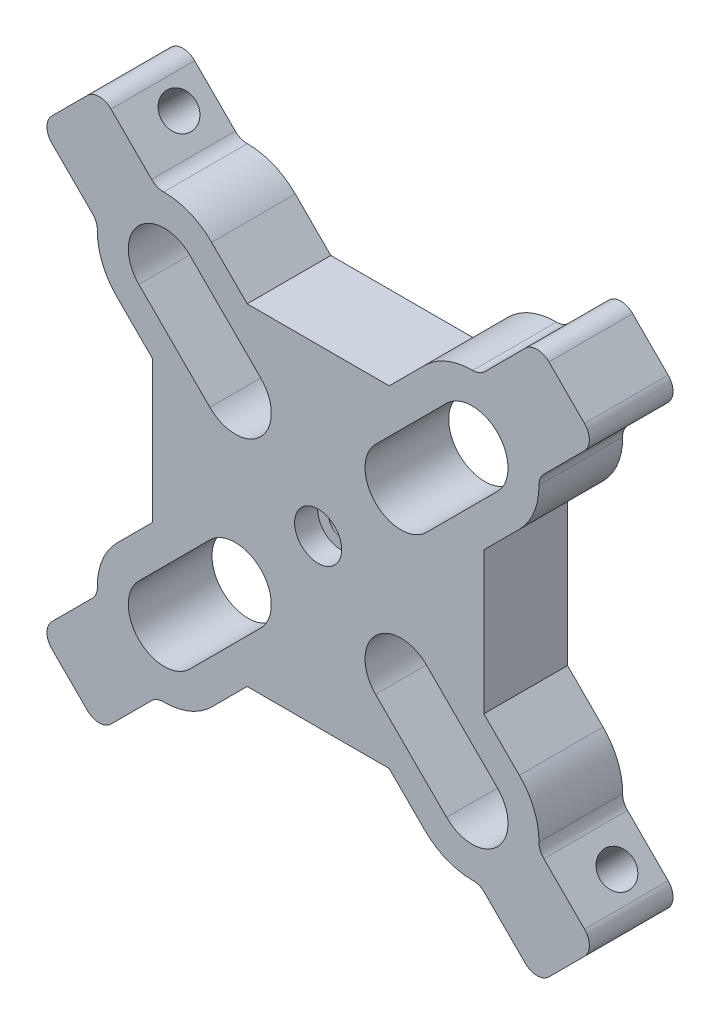
from build123d import *

# Parameters (mm, degrees)
SKETCH1_W                                      = 71.12
SKETCH1_H                                      = 71.12
EXTRUDE1_DEPTH                                 = 12.7
SKETCH3_R                                      = 2.921
CUT_EXTRUDE1_DEPTH                             = 102.377506381
MIRROR3_COPY_1_SKETCH_R                        = 2.921
MIRROR3_COPY_1_DEPTH                           = 102.377506381
MIRROR3_COPY_2_SKETCH_R                        = 2.921
MIRROR3_COPY_2_DEPTH                           = 102.377506381
SKETCH6_R                                      = 5.461
CUT_EXTRUDE3_DEPTH                             = 102.377506381
MIRROR6_COPY_1_SKETCH_R                        = 5.461
MIRROR6_COPY_1_DEPTH                           = 102.377506381
MIRROR6_COPY_2_SKETCH_R                        = 5.461
MIRROR6_COPY_2_DEPTH                           = 102.377506381
SKETCH7_W                                      = 71.12
SKETCH7_H                                      = 71.12
CUT_EXTRUDE5_DEPTH                             = 102.377506381
EXTRUDE2_DEPTH                                 = 12.7
CBORE_FOR_6_SOCKET_HEAD_CAP_SCREW1_D           = 3.7973
CBORE_FOR_6_SOCKET_HEAD_CAP_SCREW1_CBORE_D     = 7.14502
CBORE_FOR_6_SOCKET_HEAD_CAP_SCREW1_CBORE_DEPTH = 3.5052
MIRROR9_COPY_1_DEPTH                           = 12.7
FILLET3_R                                      = 2.54


with BuildPart() as part:
    # Sketch1 → Extrude1 (new body)
    with BuildSketch(Plane.XY):
        with Locations((-35.56, 35.56)):
            Rectangle(SKETCH1_W, SKETCH1_H)
    extrude(amount=EXTRUDE1_DEPTH)

    # Sketch3 → Cut-Extrude1 (cut, through all)
    with BuildSketch(Plane.XY.offset(12.7)):
        with Locations((-58.908665915, 58.908665915)):
            Circle(SKETCH3_R)
        with Locations((-48.132358569, 48.132358569)):
            Circle(SKETCH3_R)
        Polygon((-58.908665915, 58.908665915), (-56.843207007, 60.974124823), (-46.066899662, 50.197817477), (-50.197817477, 46.066899662), (-60.974124823, 56.843207007), align=None)
    cut_extrude1 = extrude(amount=-CUT_EXTRUDE1_DEPTH, mode=Mode.SUBTRACT)

    # Mirror1: Cut-Extrude1 across plane
    add(cut_extrude1.mirror(Plane.ZX.offset(35.56)), mode=Mode.SUBTRACT)

    # Mirror2: Cut-Extrude1 across plane
    add(cut_extrude1.mirror(Plane(origin=(-35.56, 0, 0), x_dir=(0, 0, 1), z_dir=(1, 0, 0))), mode=Mode.SUBTRACT)

    # Mirror3 copy 1 sketch → Mirror3 copy 1 (cut, through all)
    with BuildSketch(Plane(origin=(-71.12, 71.12, 12.7), x_dir=(-1, 0, 0), z_dir=(0, 0, 1))):
        with Locations((-58.908665915, 58.908665915)):
            Circle(MIRROR3_COPY_1_SKETCH_R)
        with Locations((-48.132358569, 48.132358569)):
            Circle(MIRROR3_COPY_1_SKETCH_R)
        Polygon((-58.908665915, 58.908665915), (-56.843207007, 60.974124823), (-46.066899662, 50.197817477), (-50.197817477, 46.066899662), (-60.974124823, 56.843207007), align=None)
    extrude(amount=-MIRROR3_COPY_1_DEPTH, mode=Mode.SUBTRACT)

    # Mirror3 copy 2 sketch → Mirror3 copy 2 (cut, through all)
    with BuildSketch(Plane(origin=(0, 71.12, 12.7), x_dir=(1, 0, 0), z_dir=(0, 0, 1))):
        with Locations((-58.908665915, -58.908665915)):
            Circle(MIRROR3_COPY_2_SKETCH_R)
        with Locations((-48.132358569, -48.132358569)):
            Circle(MIRROR3_COPY_2_SKETCH_R)
        Polygon((-58.908665915, -58.908665915), (-56.843207007, -60.974124823), (-46.066899662, -50.197817477), (-50.197817477, -46.066899662), (-60.974124823, -56.843207007), align=None)
    extrude(amount=-MIRROR3_COPY_2_DEPTH, mode=Mode.SUBTRACT)

    # Sketch6 → Cut-Extrude3 (cut, through all)
    with BuildSketch(Plane.XY.offset(12.7)):
        with Locations((-58.908665915, 58.908665915)):
            Circle(SKETCH6_R)
        with Locations((-48.132358569, 48.132358569)):
            Circle(SKETCH6_R)
        Polygon((-58.908665915, 58.908665915), (-55.047155783, 62.770176047), (-44.270848437, 51.993868702), (-48.132358569, 48.132358569), (-51.993868702, 44.270848437), (-62.770176047, 55.047155783), align=None)
    cut_extrude3 = extrude(amount=-CUT_EXTRUDE3_DEPTH, mode=Mode.SUBTRACT)

    # Mirror4: Cut-Extrude3 across plane
    add(cut_extrude3.mirror(Plane(origin=(-35.56, 0, 0), x_dir=(0, 0, 1), z_dir=(1, 0, 0))), mode=Mode.SUBTRACT)

    # Mirror5: Cut-Extrude3 across plane
    add(cut_extrude3.mirror(Plane.ZX.offset(35.56)), mode=Mode.SUBTRACT)

    # Mirror6 copy 1 sketch → Mirror6 copy 1 (cut, through all)
    with BuildSketch(Plane(origin=(-71.12, 71.12, 12.7), x_dir=(-1, 0, 0), z_dir=(0, 0, 1))):
        with Locations((-58.908665915, 58.908665915)):
            Circle(MIRROR6_COPY_1_SKETCH_R)
        with Locations((-48.132358569, 48.132358569)):
            Circle(MIRROR6_COPY_1_SKETCH_R)
        Polygon((-58.908665915, 58.908665915), (-55.047155783, 62.770176047), (-44.270848437, 51.993868702), (-48.132358569, 48.132358569), (-51.993868702, 44.270848437), (-62.770176047, 55.047155783), align=None)
    extrude(amount=-MIRROR6_COPY_1_DEPTH, mode=Mode.SUBTRACT)

    # Mirror6 copy 2 sketch → Mirror6 copy 2 (cut, through all)
    with BuildSketch(Plane(origin=(-71.12, 0, 12.7), x_dir=(-1, 0, 0), z_dir=(0, 0, 1))):
        with Locations((-58.908665915, -58.908665915)):
            Circle(MIRROR6_COPY_2_SKETCH_R)
        with Locations((-48.132358569, -48.132358569)):
            Circle(MIRROR6_COPY_2_SKETCH_R)
        Polygon((-58.908665915, -58.908665915), (-55.047155783, -62.770176047), (-44.270848437, -51.993868702), (-48.132358569, -48.132358569), (-51.993868702, -44.270848437), (-62.770176047, -55.047155783), align=None)
    extrude(amount=-MIRROR6_COPY_2_DEPTH, mode=Mode.SUBTRACT)

    # Sketch7 → Cut-Extrude5 (cut, through all)
    with BuildSketch(Plane.XY.offset(12.7)):
        with Locations((-35.56, 35.56)):
            Rectangle(SKETCH7_W, SKETCH7_H)
        with BuildLine():
            Line((-10.415282861, 24.783692655), (-5.027129188, 19.395538982))
            ThreePointArc((-5.027129188, 19.395538982), (-2.824718035, 16.099397758), (-2.051334085, 12.211334085))
            ThreePointArc((-2.051334085, 12.211334085), (-8.323270412, 2.824718035), (-19.395538982, 5.027129188))
            Line((-19.395538982, 5.027129188), (-24.783692655, 10.415282861))
            Line((-24.783692655, 10.415282861), (-46.336307345, 10.415282861))
            Line((-46.336307345, 10.415282861), (-51.724461018, 5.027129188))
            ThreePointArc((-51.724461018, 5.027129188), (-66.092870812, 5.027129188), (-66.092870812, 19.395538982))
            Line((-66.092870812, 19.395538982), (-60.704717139, 24.783692655))
            Line((-60.704717139, 24.783692655), (-60.704717139, 46.336307345))
            Line((-60.704717139, 46.336307345), (-66.092870812, 51.724461018))
            ThreePointArc((-66.092870812, 51.724461018), (-66.092870812, 66.092870812), (-51.724461018, 66.092870812))
            Line((-51.724461018, 66.092870812), (-46.336307345, 60.704717139))
            Line((-46.336307345, 60.704717139), (-24.783692655, 60.704717139))
            Line((-24.783692655, 60.704717139), (-19.395538982, 66.092870812))
            ThreePointArc((-19.395538982, 66.092870812), (-8.323270412, 68.295281965), (-2.051334085, 58.908665915))
            ThreePointArc((-2.051334085, 58.908665915), (-2.824718035, 55.020602242), (-5.027129188, 51.724461018))
            Line((-5.027129188, 51.724461018), (-10.415282861, 46.336307345))
            Line((-10.415282861, 46.336307345), (-10.415282861, 24.783692655))
        make_face(mode=Mode.SUBTRACT)
    extrude(amount=-CUT_EXTRUDE5_DEPTH, mode=Mode.SUBTRACT)

    # Sketch10 → Extrude2 (add)
    with BuildSketch(Plane.XY.offset(12.7)):
        Polygon((-68.786947648, 59.806691527), (-59.806691527, 68.786947648), (-68.786947648, 77.767203769), (-77.767203769, 68.786947648), align=None)
    extrude2 = extrude(amount=-EXTRUDE2_DEPTH)

    # CBORE for _6 Socket Head Cap Screw1 (through all)
    with Locations(Plane(origin=(-35.561282861, 35.558717139, 12.7), x_dir=(1, 0, 0), z_dir=(0, 0, 1))):
        with Locations((0, 0)):
            CounterBoreHole(CBORE_FOR_6_SOCKET_HEAD_CAP_SCREW1_D / 2, CBORE_FOR_6_SOCKET_HEAD_CAP_SCREW1_CBORE_D / 2, CBORE_FOR_6_SOCKET_HEAD_CAP_SCREW1_CBORE_DEPTH)

    # Sketch15 → 6 _0.204_ Diameter Hole1 (revolve, cut)
    with BuildSketch(Plane(origin=(-64.296819587, 73.277075708, 5.08), x_dir=(-0.7071067811865476, 0.7071067811865476, 0), z_dir=(0, 0, 1))):
        Polygon((0, 0), (0, 67.596709692), (2.5908, 66.04), (2.5908, 0), align=None)
    f_6_0_204_diameter_hole1 = revolve(axis=Axis((-59.806691527, 77.767203769, 5.08), (-0.7071067811865476, -0.7071067811865476, 0)), mode=Mode.SUBTRACT)

    # Mirror8: Extrude2, 6 _0.204_ Diameter Hole1 across plane
    add(extrude2.mirror(Plane.ZX.offset(35.56)))
    add(f_6_0_204_diameter_hole1.mirror(Plane.ZX.offset(35.56)), mode=Mode.SUBTRACT)

    # Mirror9: Extrude2, 6 _0.204_ Diameter Hole1 across plane
    add(extrude2.mirror(Plane(origin=(-35.56, 0, 0), x_dir=(0, 0, 1), z_dir=(1, 0, 0))))
    add(f_6_0_204_diameter_hole1.mirror(Plane(origin=(-35.56, 0, 0), x_dir=(0, 0, 1), z_dir=(1, 0, 0))), mode=Mode.SUBTRACT)

    # Mirror9 copy 1 sketch → Mirror9 copy 1 (add)
    with BuildSketch(Plane(origin=(-71.12, 71.12, 12.7), x_dir=(-1, 0, 0), z_dir=(0, 0, 1))):
        Polygon((-68.786947648, 59.806691527), (-59.806691527, 68.786947648), (-68.786947648, 77.767203769), (-77.767203769, 68.786947648), align=None)
    extrude(amount=-MIRROR9_COPY_1_DEPTH)

    # Mirror9 copy 2 sketch → Mirror9 copy 2 (revolve, cut)
    with BuildSketch(Plane(origin=(-6.823180413, -2.157075708, 5.08), x_dir=(0.7071067811865476, -0.7071067811865476, 0), z_dir=(0, 0, 1))):
        Polygon((0, 0), (0, 67.596709692), (2.5908, 66.04), (2.5908, 0), align=None)
    revolve(axis=Axis((-11.313308473, -6.647203769, 5.08), (0.7071067811865476, 0.7071067811865476, 0)), mode=Mode.SUBTRACT)

    # Fillet3
    fillet3_edges = [part.edges().sort_by_distance(p)[0] for p in [
        (-2.113037875, 11.093293996, 6.35),
        (-11.093293996, 2.113037875, 6.35),
        (-60.026706004, 2.113037875, 6.35),
        (-69.006962125, 11.093293996, 6.35),
        (-69.006962125, 60.026706004, 6.35),
        (-60.026706004, 69.006962125, 6.35),
        (-11.093293996, 69.006962125, 6.35),
        (-2.113037875, 60.026706004, 6.35),
        (6.647203769, 2.333052352, 6.35),
        (-2.333052352, -6.647203769, 6.35),
        (-68.786947648, -6.647203769, 6.35),
        (-77.767203769, 2.333052352, 6.35),
        (-77.767203769, 68.786947648, 6.35),
        (-68.786947648, 77.767203769, 6.35),
        (-2.333052352, 77.767203769, 6.35),
        (6.647203769, 68.786947648, 6.35),
    ]]
    fillet(fillet3_edges, radius=FILLET3_R)


solid = part.part
